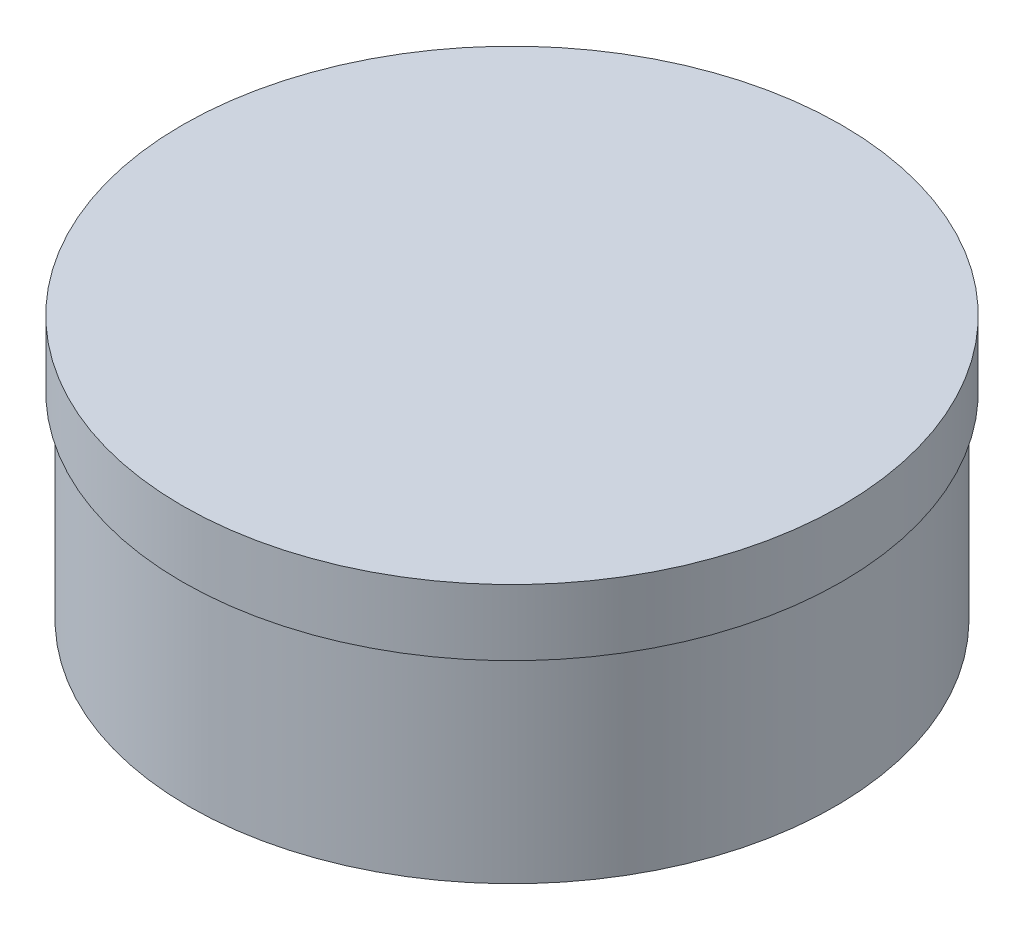
from build123d import *

# Parameters (mm, degrees)
SKETCH1_R           = 4.9
SKETCH1_R_2         = 3.8
BOSS_EXTRUDE1_DEPTH = 3
SKETCH2_R           = 5
BOSS_EXTRUDE2_DEPTH = 1
CHAMFER1_SIZE       = 0.5


with BuildPart() as part:
    # Sketch1 → Boss-Extrude1 (new body)
    with BuildSketch(Plane(origin=(0, 0, 0), x_dir=(1, 0, 0), z_dir=(0, 1, 0))):
        Circle(SKETCH1_R)
        Circle(SKETCH1_R_2, mode=Mode.SUBTRACT)
    extrude(amount=BOSS_EXTRUDE1_DEPTH)

    # Sketch2 → Boss-Extrude2 (add)
    with BuildSketch(Plane(origin=(0, 3, 0), x_dir=(1, 0, 0), z_dir=(0, 1, 0))):
        Circle(SKETCH2_R)
    extrude(amount=BOSS_EXTRUDE2_DEPTH)

    # Chamfer1
    chamfer1_edges = [part.edges().sort_by_distance(p)[0] for p in [
        (-3.8, 0, 0),
    ]]
    chamfer(chamfer1_edges, length=CHAMFER1_SIZE)


solid = part.part
